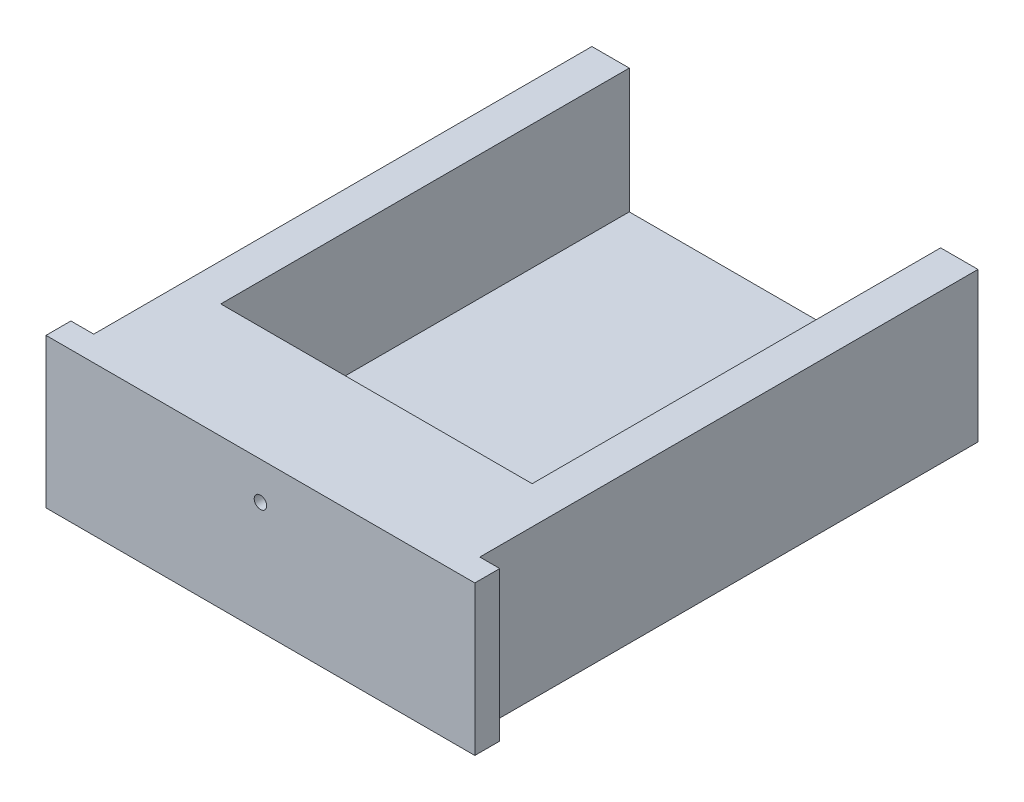
from build123d import *

# Parameters (mm, degrees)
BOSS_EXTRUDE1_DEPTH       = 20
SKETCH4_W                 = 17.215870058
SKETCH4_H                 = 6
BOSS_EXTRUDE2_DEPTH       = 1
BOSS_EXTRUDE3_DEPTH       = 3.6
F_1_0MM_DOWEL_HOLE1_D     = 0.5
F_1_0MM_DOWEL_HOLE1_DEPTH = 4.6


with BuildPart() as part:
    # Sketch3 → Boss-Extrude1 (new body)
    with BuildSketch(Plane(origin=(-3.4e-08, 0.000254638, -31.967040172), x_dir=(1, 0, -1e-09), z_dir=(1e-09, -7.966e-06, 1))):
        Polygon((98.980598041, 85.65676806), (114.480598041, 85.65676806), (114.480601842, 91.65676711), (112.980601807, 91.65676806), (112.980601807, 86.65676806), (100.480601842, 86.65676806), (100.480601842, 91.65676806), (98.980601842, 91.65676806), align=None)
    extrude(amount=BOSS_EXTRUDE1_DEPTH)

    # Sketch4 → Boss-Extrude2 (add)
    with BuildSketch(Plane(origin=(-1.3e-08, 9.5325e-05, -11.967040173), x_dir=(1, 0, -1e-09), z_dir=(1e-09, -7.966e-06, 1))):
        with Locations((106.672666813, 88.65676806)):
            Rectangle(SKETCH4_W, SKETCH4_H)
    extrude(amount=BOSS_EXTRUDE2_DEPTH)

    # Sketch7 → Boss-Extrude3 (add)
    with BuildSketch(Plane(origin=(-1.3e-08, 9.5325e-05, -11.967040173), x_dir=(-1, 0, 1e-09), z_dir=(-1e-09, 7.966e-06, -1))):
        Polygon((-112.980601816, 91.65676806), (-112.980601825, 86.65676806), (-100.480601842, 86.65676806), (-100.480601851, 91.65676806), align=None)
    extrude(amount=BOSS_EXTRUDE3_DEPTH)

    # Ø1.0mm Dowel Hole1
    with Locations(Plane(origin=(-1.2e-08, 8.7359e-05, -10.967040173), x_dir=(1, 0, -1e-09), z_dir=(1e-09, -7.966e-06, 1))):
        with Locations((106.672666813, 90.15676806)):
            Hole(F_1_0MM_DOWEL_HOLE1_D / 2, depth=F_1_0MM_DOWEL_HOLE1_DEPTH)


solid = part.part
